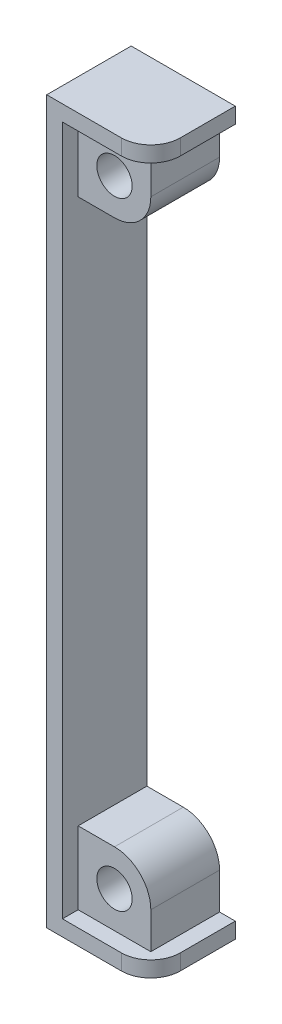
from build123d import *

# Parameters (mm, degrees)
SKETCH_1_R        = 1.8
EXTRUDE_1_DEPTH   = 7
EXTRUDE_1_2_DEPTH = 7
EXTRUDE_2_DEPTH   = 8.6
FILLET_1_R        = 3


with BuildPart() as part:
    # Эскиз1 → Бобышка-Вытянуть1 (new body)
    with BuildSketch(Plane.XY):
        with BuildLine():
            ThreePointArc((9, 5.3), (7.91629509, 7.91629509), (5.3, 9))
            Line((5.3, 9), (1.6, 9))
            Line((1.6, 9), (1.6, 1.6))
            Line((1.6, 1.6), (9, 1.6))
            Line((9, 1.6), (9, 5.3))
        make_face()
        with Locations((5.3, 5.3)):
            Circle(SKETCH_1_R, mode=Mode.SUBTRACT)
    extrude(amount=EXTRUDE_1_DEPTH)



with BuildPart() as body_2:
    # Эскиз1 → Extrude 1 2 (new body)
    with BuildSketch(Plane.XY):
        with BuildLine():
            Line((1.6, 64.465), (5.3, 64.465))
            ThreePointArc((5.3, 64.465), (7.91629509, 65.54870491), (9, 68.165))
            Line((9, 68.165), (9, 71.865))
            Line((9, 71.865), (1.6, 71.865))
            Line((1.6, 71.865), (1.6, 64.465))
        make_face()
        with Locations((5.3, 68.165)):
            Circle(SKETCH_1_R, mode=Mode.SUBTRACT)
    extrude(amount=EXTRUDE_1_2_DEPTH)


with BuildPart() as part_1:
    add(part.part)

    add(body_2.part)  # Бобышка-Вытянуть2 merges body 2
    # Эскиз1<3> → Бобышка-Вытянуть2 (add)
    with BuildSketch(Plane.XY):
        Polygon((1.6, 71.865), (10.6, 71.865), (10.6, 73.465), (0, 73.465), (0, 0), (10.6, 0), (10.6, 1.6), (1.6, 1.6), align=None)
    extrude(amount=EXTRUDE_2_DEPTH)

    # Скругление1
    fillet_1_edges = [part_1.edges().sort_by_distance(p)[0] for p in [
        (10.6, 0.8, 8.6),
        (10.6, 72.665, 8.6),
    ]]
    fillet(fillet_1_edges, radius=FILLET_1_R)


solid = part_1.part
